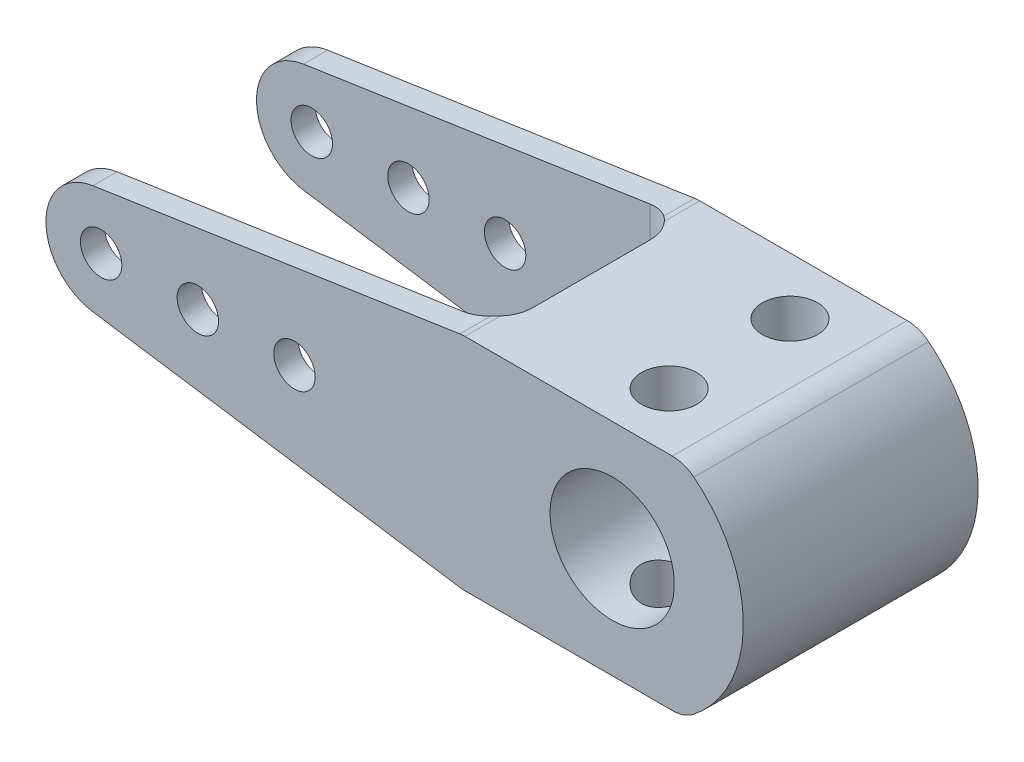
from build123d import *

# Parameters (mm, degrees)
SKETCH_1_R          = 3
SKETCH_1_W          = 32
SKETCH_1_H          = 31.908510126
EXTRUDE_1_DEPTH     = 34
CUT_EXTRUDE_START   = -3.5
SKETCH_4_W          = 70
SKETCH_4_H          = 50
CUT_EXTRUDE_3_DEPTH = 27
FILLET_1_R          = 5
SKETCH_3_R          = 9
CUT_EXTRUDE_5_DEPTH = 35
SKETCH_8_R          = 4
CUT_EXTRUDE_6_DEPTH = 20
FILLET_2_R          = 5


with BuildPart() as part:
    # 草圖1 → 填料-伸長1 (new body)
    with BuildSketch(Plane.XY):
        with BuildLine():
            Line((-21.681969888, -15.954255063), (-21.681969888, 15.954255063))
            Line((-21.681969888, 15.954255063), (-75.189189189, 7.911120595))
            ThreePointArc((-75.189189189, 7.911120595), (-82, 0), (-75.189189189, -7.911120595))
            Line((-75.189189189, -7.911120595), (-21.681969888, -15.954255063))
        make_face()
        with Locations((-74, 0)):
            Circle(SKETCH_1_R, mode=Mode.SUBTRACT)
        with Locations((-60, 0)):
            Circle(SKETCH_1_R, mode=Mode.SUBTRACT)
        with Locations((-46, 0)):
            Circle(SKETCH_1_R, mode=Mode.SUBTRACT)
        with Locations((-5.681969888, 0)):
            Rectangle(SKETCH_1_W, SKETCH_1_H)
        with BuildLine():
            ThreePointArc((10.318030112, -15.954255063), (19, 0), (10.318030112, 15.954255063))
            Line((10.318030112, 15.954255063), (10.318030112, -15.954255063))
        make_face()
    extrude(amount=EXTRUDE_1_DEPTH)

    # 草圖4 → 除料-伸長3 (cut)
    with BuildSketch(Plane(origin=(0, 0, 0), x_dir=(-1, 0, 0), z_dir=(0, 0, -1)).offset(CUT_EXTRUDE_START)):
        with Locations((55, 0)):
            Rectangle(SKETCH_4_W, SKETCH_4_H)
    extrude(amount=-CUT_EXTRUDE_3_DEPTH, mode=Mode.SUBTRACT)

    # 圓角1
    fillet_1_edges = [part.edges().sort_by_distance(p)[0] for p in [
        (-20, 0, 3.5),
        (-20, 0, 30.5),
    ]]
    fillet(fillet_1_edges, radius=FILLET_1_R)

    # 草圖3 → 除料-伸長5 (cut, through all)
    with BuildSketch(Plane(origin=(0, 0, 0), x_dir=(-1, 0, 0), z_dir=(0, 0, -1))):
        Circle(SKETCH_3_R)
    extrude(amount=-CUT_EXTRUDE_5_DEPTH, mode=Mode.SUBTRACT)

    # 草圖8 → 除料-伸長6 (cut, symmetric)
    with BuildSketch(Plane(origin=(0, 0, 0), x_dir=(1, 0, 0), z_dir=(0, 1, 0))):
        with Locations((0, -25.75)):
            Circle(SKETCH_8_R)
        with Locations((0, -8.25)):
            Circle(SKETCH_8_R)
    extrude(amount=CUT_EXTRUDE_6_DEPTH, both=True, mode=Mode.SUBTRACT)

    # 圓角2
    fillet_2_edges = [part.edges().sort_by_distance(p)[0] for p in [
        (-21.681969888, -15.954255063, 2.379794385),
        (-21.681969888, -15.954255063, 31.620205615),
        (-21.681969888, 15.954255063, 2.379794385),
        (-21.681969888, 15.954255063, 31.620205615),
        (10.318030112, -15.954255063, 17),
        (10.318030112, 15.954255063, 17),
    ]]
    fillet(fillet_2_edges, radius=FILLET_2_R)


solid = part.part
